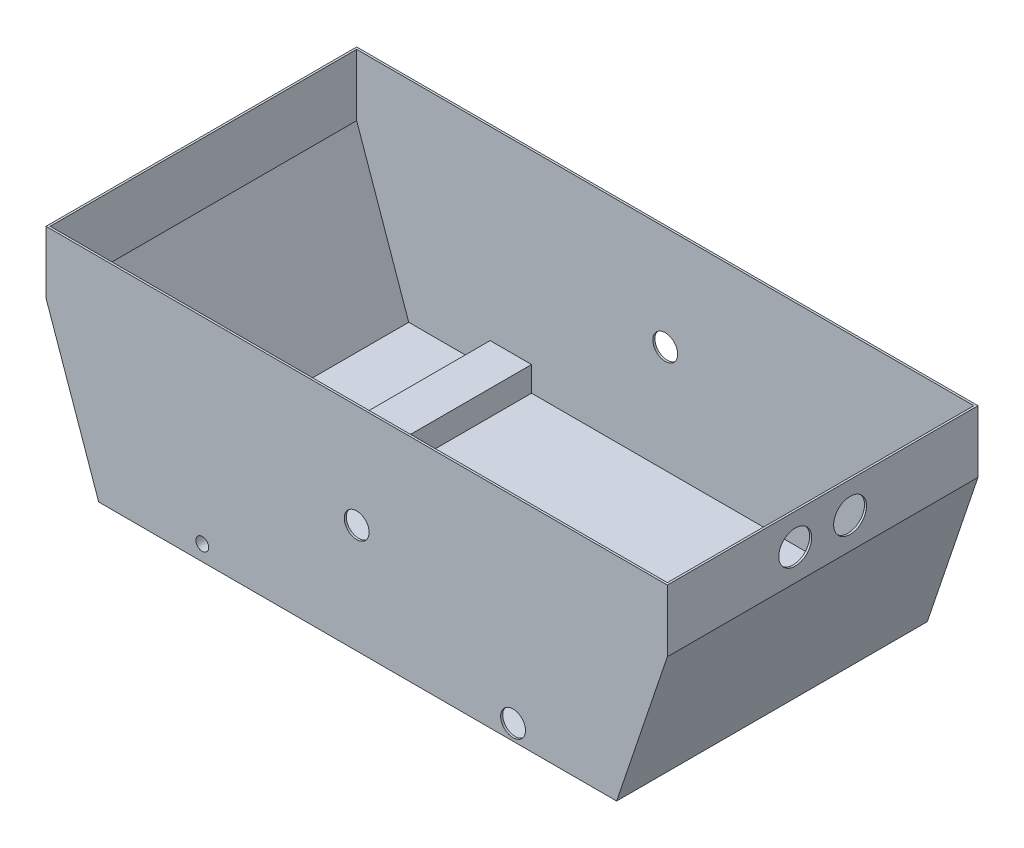
from build123d import *

# Parameters (mm, degrees)
BOSS_EXTRUDE1_DEPTH     = 15
SCALE4_SCALE            = 10
SHELL3_T                = -1
SKETCH7_R               = 2.5
CUT_EXTRUDE2_DEPTH      = 1
CUT_EXTRUDE2_DEPTH_BACK = 151
SKETCH8_R               = 2.5
CUT_EXTRUDE3_DEPTH      = 1
CUT_EXTRUDE3_DEPTH_BACK = 151
SKETCH11_R              = 6
CUT_EXTRUDE5_DEPTH      = 1
CUT_EXTRUDE5_DEPTH_BACK = 151
SKETCH12_R              = 6
CUT_EXTRUDE6_DEPTH      = 1
CUT_EXTRUDE6_DEPTH_BACK = 151
SKETCH19_W              = 20
SKETCH19_H              = 148
BOSS_EXTRUDE6_DEPTH     = 12
SKETCH6_R               = 3.1
CUT_EXTRUDE9_DEPTH      = 1
CUT_EXTRUDE9_DEPTH_BACK = 151
SKETCH22_R              = 7.95
CUT_EXTRUDE10_DEPTH     = 2


with BuildPart() as part:
    # Sketch1 → Boss-Extrude1 (new body)
    with BuildSketch(Plane.XY):
        Polygon((-49.791399094, 32.645333647), (-19.791399094, 32.645333647), (-19.791399094, 29.645333647), (-22.238991949, 22.388566018), (-47.247714564, 22.388566018), (-49.791399094, 29.645333647), align=None)
    extrude(amount=BOSS_EXTRUDE1_DEPTH)


with BuildPart() as part_1:
    # Scale4: scaled about (-34.775342822, 27.686391484, 7.5)
    add(part.part.scale(SCALE4_SCALE).moved(Location((312.978085398, -249.177523356, -67.5))))

    # Shell3
    shell3_openings = [part_1.faces().sort_by_distance(p)[0] for p in [
        (-34.935905541, 77.275813113, 7.5),
    ]]
    offset(amount=SHELL3_T, openings=shell3_openings, kind=Kind.INTERSECTION)

    # Sketch7 → Cut-Extrude2 (cut, two sides)
    with BuildSketch(Plane.XY.offset(82.5)) as cut_extrude2_sk:
        with Locations((40.588165903, -17.79186318)):
            Circle(SKETCH7_R)
    extrude(amount=CUT_EXTRUDE2_DEPTH, mode=Mode.SUBTRACT)
    extrude(cut_extrude2_sk.sketch, amount=-CUT_EXTRUDE2_DEPTH_BACK, mode=Mode.SUBTRACT)

    # Sketch8 → Cut-Extrude3 (cut, two sides)
    with BuildSketch(Plane.XY.offset(82.5)) as cut_extrude3_sk:
        with Locations((-34.935905541, 27.275813113)):
            Circle(SKETCH8_R)
    extrude(amount=CUT_EXTRUDE3_DEPTH, mode=Mode.SUBTRACT)
    extrude(cut_extrude3_sk.sketch, amount=-CUT_EXTRUDE3_DEPTH_BACK, mode=Mode.SUBTRACT)

    # Sketch11 → Cut-Extrude5 (cut, two sides)
    with BuildSketch(Plane(origin=(0, 0, -67.5), x_dir=(-1, 0, 0), z_dir=(0, 0, -1))) as cut_extrude5_sk:
        with Locations((-40.588165903, -17.79186318)):
            Circle(SKETCH11_R)
    extrude(amount=CUT_EXTRUDE5_DEPTH, mode=Mode.SUBTRACT)
    extrude(cut_extrude5_sk.sketch, amount=-CUT_EXTRUDE5_DEPTH_BACK, mode=Mode.SUBTRACT)

    # Sketch12 → Cut-Extrude6 (cut, two sides)
    with BuildSketch(Plane.XY.offset(82.5)) as cut_extrude6_sk:
        with Locations((-34.935905541, 27.275813113)):
            Circle(SKETCH12_R)
    extrude(amount=CUT_EXTRUDE6_DEPTH, mode=Mode.SUBTRACT)
    extrude(cut_extrude6_sk.sketch, amount=-CUT_EXTRUDE6_DEPTH_BACK, mode=Mode.SUBTRACT)

    # Sketch19 → Boss-Extrude6 (add)
    with BuildSketch(Plane(origin=(0, -24.29186318, 0), x_dir=(1, 0, 0), z_dir=(0, 1, 0))):
        with Locations((-109.499060243, -7.5)):
            Rectangle(SKETCH19_W, SKETCH19_H)
    extrude(amount=BOSS_EXTRUDE6_DEPTH)

    # Sketch6 → Cut-Extrude9 (cut, two sides)
    with BuildSketch(Plane.XY.offset(82.5)) as cut_extrude9_sk:
        with Locations((-109.499060243, -17.79186318)):
            Circle(SKETCH6_R)
    extrude(amount=CUT_EXTRUDE9_DEPTH, mode=Mode.SUBTRACT)
    extrude(cut_extrude9_sk.sketch, amount=-CUT_EXTRUDE9_DEPTH_BACK, mode=Mode.SUBTRACT)

    # Sketch22 → Cut-Extrude10 (cut)
    with BuildSketch(Plane(origin=(115.064094459, 0, 0), x_dir=(0, 0, -1), z_dir=(1, 0, 0))):
        with Locations((-20.75, 62.275813113)):
            Circle(SKETCH22_R)
        with Locations((5.75, 62.275813113)):
            Circle(SKETCH22_R)
    extrude(amount=-CUT_EXTRUDE10_DEPTH, mode=Mode.SUBTRACT)


solid = part_1.part
